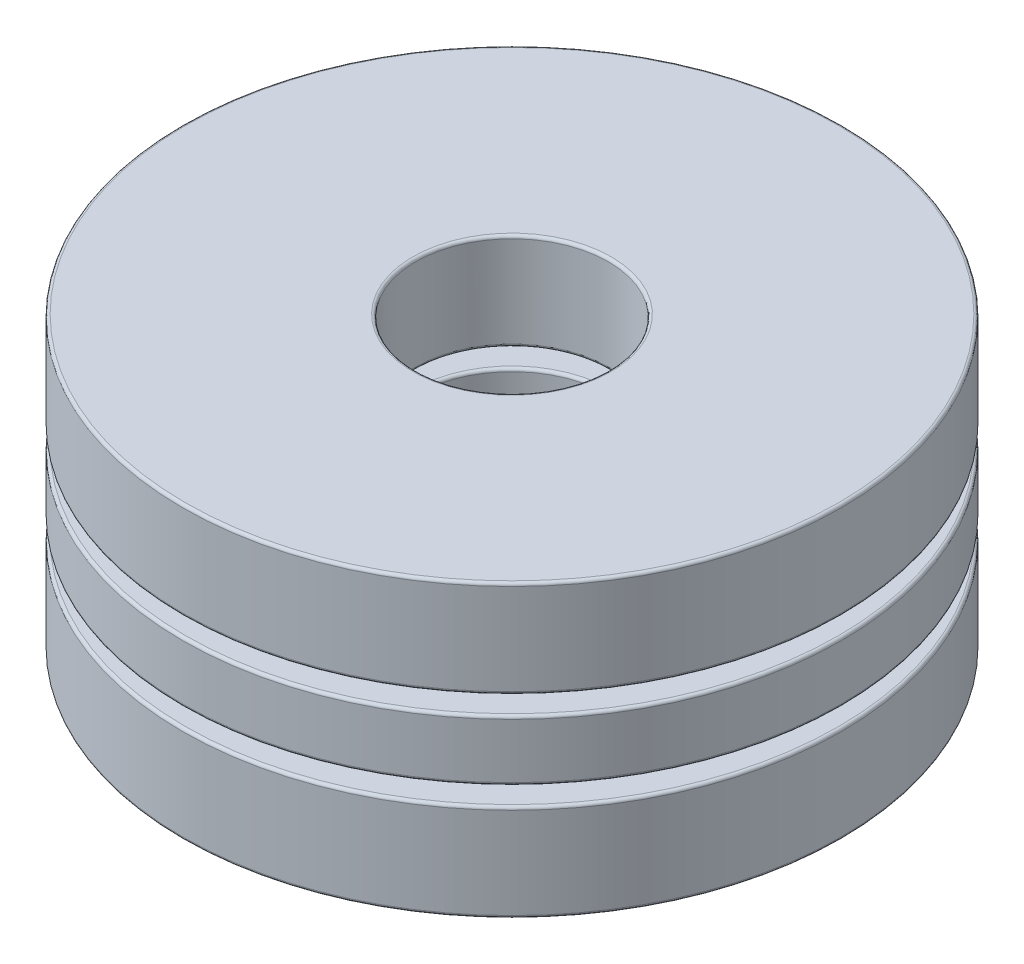
from build123d import *

# Parameters (mm, degrees)
SKETCH1_W         = 3.93065
SKETCH1_H         = 1.021291666
CIRPATTERN1_COUNT = 2
CIRPATTERN1_ANGLE = 180
CIRPATTERN2_COUNT = 2
SKETCH4_W         = 3.93065
SKETCH4_H         = 1.634066667
FILLET1_R         = 0.049022
FILLET2_R         = 0.049022
FILLET3_R         = 0.049022


with BuildPart() as part:
    # Sketch1 → Revolve1 (revolve)
    with BuildSketch(Plane(origin=(0, 0, 0), x_dir=(0, 0, -1), z_dir=(1, 0, 0))):
        with Locations((-3.590925, 0)):
            Rectangle(SKETCH1_W, SKETCH1_H)
    revolve(axis=Axis((0, -2.4511, 0), (0, 1, 0)))

    # Sketch3 → Cut-Revolve1 (revolve, cut)
    with BuildSketch(Plane(origin=(0, 0, 0), x_dir=(0, 0, -1), z_dir=(1, 0, 0))):
        with BuildLine():
            Line((-3.590925, 0.817033333), (-3.590925, -0.817033333))
            ThreePointArc((-3.590925, -0.817033333), (-4.407958333, 0), (-3.590925, 0.817033333))
        make_face()
    cut_revolve1 = revolve(axis=Axis((0, 0.817033333, 3.590925), (0, -1, 0)), mode=Mode.SUBTRACT)

    # CirPattern2: Cut-Revolve1 ×2 about axis
    cirpattern2_axis = Axis((0, 2.4511, 0), (0, -1, 0))
    for i in range(1, CIRPATTERN2_COUNT):
        add(cut_revolve1.rotate(cirpattern2_axis, i * 360 / CIRPATTERN2_COUNT), mode=Mode.SUBTRACT)

    # Fillet2
    fillet2_edges = [part.edges().sort_by_distance(p)[0] for p in [
        (0, 0.510645833, -5.55625),
        (0, 0.510645833, -1.6256),
        (0, -0.510645833, -1.6256),
        (0, -0.510645833, -5.55625),
    ]]
    fillet(fillet2_edges, radius=FILLET2_R)


with BuildPart() as body_2:
    # Sketch2 → Revolve2 (revolve)
    with BuildSketch(Plane(origin=(0, 0, 0), x_dir=(0, 0, -1), z_dir=(1, 0, 0))):
        with BuildLine():
            Line((-3.590925, 0.817033333), (-3.590925, -0.817033333))
            ThreePointArc((-3.590925, -0.817033333), (-4.407958333, 0), (-3.590925, 0.817033333))
        make_face()
    revolve(axis=Axis((0, 0.817033333, 3.590925), (0, -1, 0)))


with BuildPart() as cirpattern1_1:
    # CirPattern1: pattern copy
    add(body_2.part.rotate(Axis((0, 2.4511, 0), (0, -1, 0)), 1 * CIRPATTERN1_ANGLE / (CIRPATTERN1_COUNT - 1)))


with BuildPart() as body_4:
    # Sketch4 → Revolve3 (revolve)
    with BuildSketch(Plane(origin=(0, 0, 0), x_dir=(0, 0, -1), z_dir=(1, 0, 0))):
        with Locations((-3.590925, 1.634066667)):
            Rectangle(SKETCH4_W, SKETCH4_H)
        with Locations((-3.590925, -1.634066667)):
            Rectangle(SKETCH4_W, SKETCH4_H)
    revolve(axis=Axis((0, -2.4511, 0), (0, 1, 0)))

    # Fillet1
    fillet1_edges = [body_4.edges().sort_by_distance(p)[0] for p in [
        (0, 0.817033333, -5.55625),
        (0, 0.817033333, -1.6256),
        (0, 2.4511, -1.6256),
        (0, 2.4511, -5.55625),
    ]]
    fillet(fillet1_edges, radius=FILLET1_R)

    # Fillet3
    fillet3_edges = [body_4.edges().sort_by_distance(p)[0] for p in [
        (0, -2.4511, -5.55625),
        (0, -2.4511, -1.6256),
        (0, -0.817033333, -1.6256),
        (0, -0.817033333, -5.55625),
    ]]
    fillet(fillet3_edges, radius=FILLET3_R)


solid = Compound([part.part, body_2.part, cirpattern1_1.part, body_4.part])
